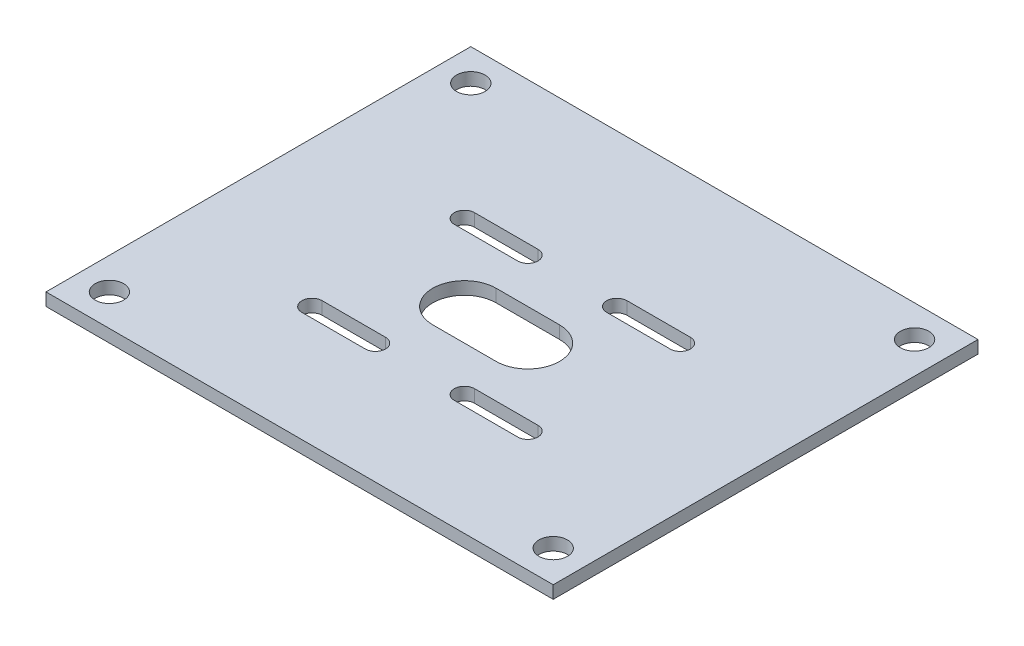
from build123d import *

# Parameters (mm, degrees)
SKETCH1_W           = 80
SKETCH1_H           = 67
SKETCH1_R           = 2.25
BOSS_EXTRUDE1_DEPTH = 2


with BuildPart() as part:
    # Sketch1 → Boss-Extrude1 (new body)
    with BuildSketch(Plane(origin=(0, 0, 0), x_dir=(1, 0, 0), z_dir=(0, 1, 0))):
        with Locations((-5, 2.5)):
            Rectangle(SKETCH1_W, SKETCH1_H)
        with Locations((30, -26)):
            Circle(SKETCH1_R, mode=Mode.SUBTRACT)
        with Locations((-40, -26)):
            Circle(SKETCH1_R, mode=Mode.SUBTRACT)
        with Locations((-40, 31)):
            Circle(SKETCH1_R, mode=Mode.SUBTRACT)
        with Locations((30, 31)):
            Circle(SKETCH1_R, mode=Mode.SUBTRACT)
        with BuildLine():
            Line((-22.02081528, 13.62081528), (-12.02081528, 13.62081528))
            ThreePointArc((-12.02081528, 13.62081528), (-10.42081528, 12.02081528), (-12.02081528, 10.42081528))
            Line((-12.02081528, 10.42081528), (-22.02081528, 10.42081528))
            ThreePointArc((-22.02081528, 10.42081528), (-23.62081528, 12.02081528), (-22.02081528, 13.62081528))
        make_face(mode=Mode.SUBTRACT)
        with BuildLine():
            Line((2.02081528, 13.62081528), (12.02081528, 13.62081528))
            ThreePointArc((12.02081528, 13.62081528), (13.62081528, 12.02081528), (12.02081528, 10.42081528))
            Line((12.02081528, 10.42081528), (2.02081528, 10.42081528))
            ThreePointArc((2.02081528, 10.42081528), (0.42081528, 12.02081528), (2.02081528, 13.62081528))
        make_face(mode=Mode.SUBTRACT)
        with BuildLine():
            Line((-10, 5), (0, 5))
            ThreePointArc((0, 5), (5, 0), (0, -5))
            Line((0, -5), (-10, -5))
            ThreePointArc((-10, -5), (-15, 0), (-10, 5))
        make_face(mode=Mode.SUBTRACT)
        with BuildLine():
            Line((-22.02081528, -13.62081528), (-12.02081528, -13.62081528))
            ThreePointArc((-12.02081528, -13.62081528), (-10.42081528, -12.02081528), (-12.02081528, -10.42081528))
            Line((-12.02081528, -10.42081528), (-22.02081528, -10.42081528))
            ThreePointArc((-22.02081528, -10.42081528), (-23.62081528, -12.02081528), (-22.02081528, -13.62081528))
        make_face(mode=Mode.SUBTRACT)
        with BuildLine():
            Line((2.02081528, -13.62081528), (12.02081528, -13.62081528))
            ThreePointArc((12.02081528, -13.62081528), (13.62081528, -12.02081528), (12.02081528, -10.42081528))
            Line((12.02081528, -10.42081528), (2.02081528, -10.42081528))
            ThreePointArc((2.02081528, -10.42081528), (0.42081528, -12.02081528), (2.02081528, -13.62081528))
        make_face(mode=Mode.SUBTRACT)
    extrude(amount=BOSS_EXTRUDE1_DEPTH)


solid = part.part
